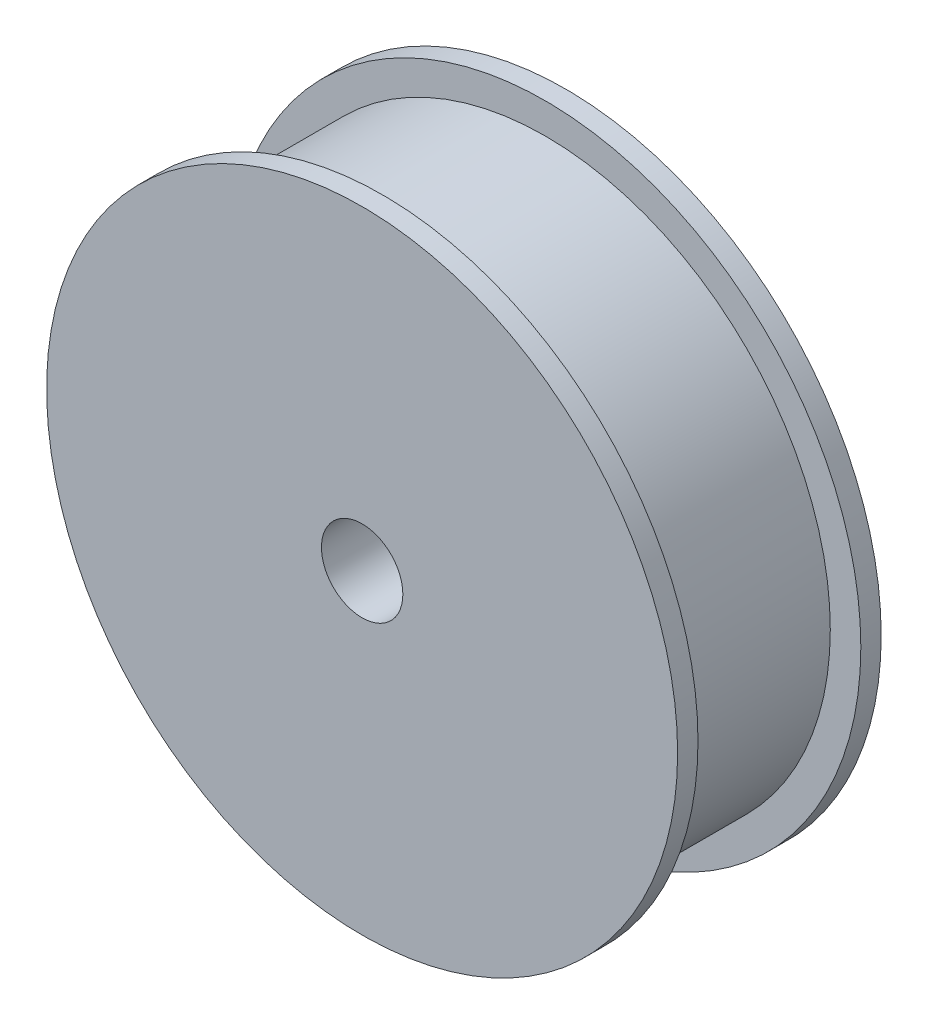
from build123d import *

# Parameters (mm, degrees)
SKETCH1_R           = 31
BOSS_EXTRUDE1_DEPTH = 20
SKETCH2_R           = 31
SKETCH2_R_2         = 28
CUT_EXTRUDE1_DEPTH  = 16
SKETCH3_R           = 4
CUT_EXTRUDE2_DEPTH  = 21


with BuildPart() as part:
    # Sketch1 → Boss-Extrude1 (new body)
    with BuildSketch(Plane(origin=(0, 0, 0), x_dir=(0, 1, 0), z_dir=(0, 0, 1))):
        Circle(SKETCH1_R)
    extrude(amount=BOSS_EXTRUDE1_DEPTH)

    # Sketch2 → Cut-Extrude1 (cut)
    with BuildSketch(Plane(origin=(0, 0, 2), x_dir=(0, 1, 0), z_dir=(0, 0, 1))):
        Circle(SKETCH2_R)
        Circle(SKETCH2_R_2, mode=Mode.SUBTRACT)
    extrude(amount=CUT_EXTRUDE1_DEPTH, mode=Mode.SUBTRACT)

    # Sketch3 → Cut-Extrude2 (cut, through all)
    with BuildSketch(Plane.XY.offset(20)):
        Circle(SKETCH3_R)
    extrude(amount=-CUT_EXTRUDE2_DEPTH, mode=Mode.SUBTRACT)


solid = part.part
